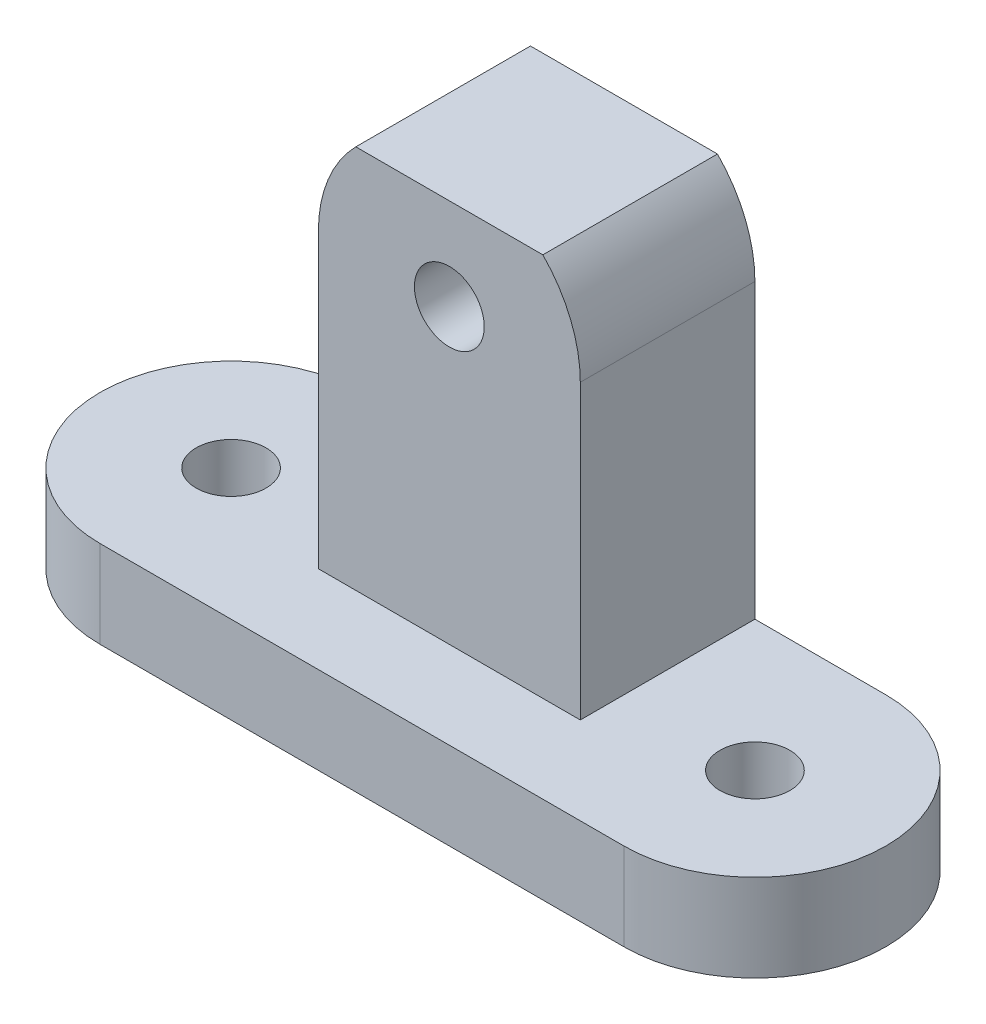
from build123d import *

# Parameters (mm, degrees)
SKETCH1_R           = 2
BOSS_EXTRUDE1_DEPTH = 5
SKETCH3_R           = 2
BOSS_EXTRUDE2_DEPTH = 10
SKETCH4_W           = 24.111622735
SKETCH4_H           = 4.195341451
CUT_EXTRUDE1_DEPTH  = 16


with BuildPart() as part:
    # Sketch1 → Boss-Extrude1 (new body)
    with BuildSketch(Plane(origin=(0, 0, 0), x_dir=(1, 0, 0), z_dir=(0, 1, 0))):
        with BuildLine():
            Line((0, 0), (30, 0))
            ThreePointArc((30, 0), (37.5, 7.5), (30, 15))
            Line((30, 15), (0, 15))
            ThreePointArc((0, 15), (-7.5, 7.5), (0, 0))
        make_face()
        with Locations((0, 7.5)):
            Circle(SKETCH1_R, mode=Mode.SUBTRACT)
        with Locations((30, 7.5)):
            Circle(SKETCH1_R, mode=Mode.SUBTRACT)
    extrude(amount=BOSS_EXTRUDE1_DEPTH)

    # Sketch3 → Boss-Extrude2 (add)
    with BuildSketch(Plane(origin=(0, 0, -15), x_dir=(-1, 0, 0), z_dir=(0, 0, -1))):
        with BuildLine():
            Line((-22.5, 5), (-7.5, 5))
            Line((-7.5, 5), (-7.5, 21.75))
            ThreePointArc((-7.5, 21.75), (-15, 29.25), (-22.5, 21.75))
            Line((-22.5, 21.75), (-22.5, 5))
        make_face()
        with Locations((-15, 21.75)):
            Circle(SKETCH3_R, mode=Mode.SUBTRACT)
    extrude(amount=-BOSS_EXTRUDE2_DEPTH)

    # Sketch4 → Cut-Extrude1 (cut, through all)
    with BuildSketch(Plane(origin=(0, 0, -15), x_dir=(-1, 0, 0), z_dir=(0, 0, -1))):
        with Locations((-13.441214338, 29.097670726)):
            Rectangle(SKETCH4_W, SKETCH4_H)
    extrude(amount=-CUT_EXTRUDE1_DEPTH, mode=Mode.SUBTRACT)


solid = part.part
